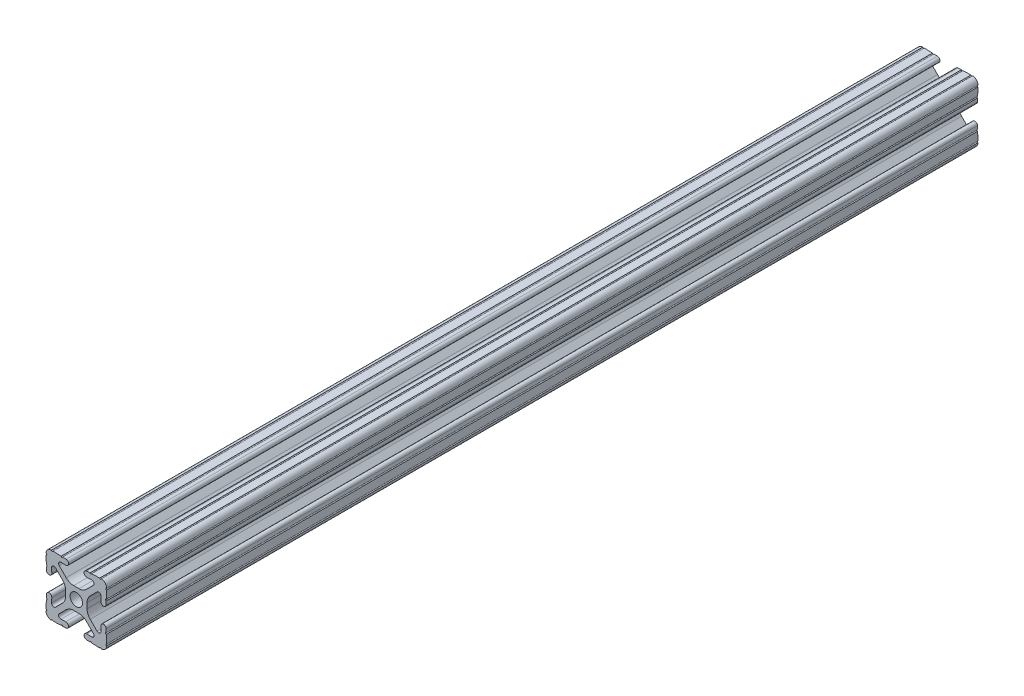
from build123d import *

# Parameters (mm, degrees)
SKETCH3_R      = 2.6035
EXTRUDE1_DEPTH = 182.5


with BuildPart() as part:
    # Sketch3 → Extrude1 (new body, symmetric)
    with BuildSketch(Plane.XY):
        with BuildLine():
            Line((-1.115277175, 4.5085), (1.115277175, 4.5085))
            ThreePointArc((1.115277175, 4.5085), (2.806584872, 4.844922018), (4.240406305, 5.80297087))
            Line((4.240406305, 5.80297087), (7.148423664, 8.710988229))
            ThreePointArc((7.148423664, 8.710988229), (7.349906316, 9.772227925), (6.436353897, 10.348636575))
            Line((6.436353897, 10.348636575), (4.381960454, 10.276895575))
            ThreePointArc((4.381960454, 10.276895575), (3.239173075, 11.342562046), (4.304839546, 12.485349424))
            Line((4.304839546, 12.485349424), (5.728246175, 12.535055879))
            ThreePointArc((5.728246175, 12.535055879), (6.054756855, 12.230579745), (6.35923299, 12.557090424))
            Line((6.35923299, 12.557090424), (9.782092278, 12.676619304))
            ThreePointArc((9.782092278, 12.676619304), (10.108602958, 12.37214317), (10.413079092, 12.69865385))
            ThreePointArc((10.413079092, 12.69865385), (12.052764565, 12.052764565), (12.69865385, 10.413079092))
            ThreePointArc((12.69865385, 10.413079092), (12.37214317, 10.108602958), (12.676619304, 9.782092278))
            Line((12.676619304, 9.782092278), (12.557090424, 6.35923299))
            ThreePointArc((12.557090424, 6.35923299), (12.230579745, 6.054756855), (12.535055879, 5.728246175))
            Line((12.535055879, 5.728246175), (12.485349424, 4.304839546))
            ThreePointArc((12.485349424, 4.304839546), (11.342562046, 3.239173075), (10.276895575, 4.381960454))
            Line((10.276895575, 4.381960454), (10.348636575, 6.436353897))
            ThreePointArc((10.348636575, 6.436353897), (9.772227925, 7.349906316), (8.710988229, 7.148423664))
            Line((8.710988229, 7.148423664), (5.80297087, 4.240406305))
            ThreePointArc((5.80297087, 4.240406305), (4.844922018, 2.806584872), (4.5085, 1.115277175))
            Line((4.5085, 1.115277175), (4.5085, -1.115277175))
            ThreePointArc((4.5085, -1.115277175), (4.844922018, -2.806584872), (5.80297087, -4.240406305))
            Line((5.80297087, -4.240406305), (8.710988229, -7.148423664))
            ThreePointArc((8.710988229, -7.148423664), (9.772227925, -7.349906316), (10.348636575, -6.436353897))
            Line((10.348636575, -6.436353897), (10.276895575, -4.381960454))
            ThreePointArc((10.276895575, -4.381960454), (11.342562046, -3.239173075), (12.485349424, -4.304839546))
            Line((12.485349424, -4.304839546), (12.535055879, -5.728246175))
            ThreePointArc((12.535055879, -5.728246175), (12.230579745, -6.054756855), (12.557090424, -6.35923299))
            Line((12.557090424, -6.35923299), (12.676619304, -9.782092278))
            ThreePointArc((12.676619304, -9.782092278), (12.37214317, -10.108602958), (12.69865385, -10.413079092))
            ThreePointArc((12.69865385, -10.413079092), (12.052764565, -12.052764565), (10.413079092, -12.69865385))
            ThreePointArc((10.413079092, -12.69865385), (10.108602958, -12.37214317), (9.782092278, -12.676619304))
            Line((9.782092278, -12.676619304), (6.35923299, -12.557090424))
            ThreePointArc((6.35923299, -12.557090424), (6.054756855, -12.230579745), (5.728246175, -12.535055879))
            Line((5.728246175, -12.535055879), (4.304839546, -12.485349424))
            ThreePointArc((4.304839546, -12.485349424), (3.239173075, -11.342562046), (4.381960454, -10.276895575))
            Line((4.381960454, -10.276895575), (6.436353897, -10.348636575))
            ThreePointArc((6.436353897, -10.348636575), (7.349906316, -9.772227925), (7.148423664, -8.710988229))
            Line((7.148423664, -8.710988229), (4.240406305, -5.80297087))
            ThreePointArc((4.240406305, -5.80297087), (2.806584872, -4.844922018), (1.115277175, -4.5085))
            Line((1.115277175, -4.5085), (-1.115277175, -4.5085))
            ThreePointArc((-1.115277175, -4.5085), (-2.806584872, -4.844922018), (-4.240406305, -5.80297087))
            Line((-4.240406305, -5.80297087), (-7.148423664, -8.710988229))
            ThreePointArc((-7.148423664, -8.710988229), (-7.349906316, -9.772227925), (-6.436353897, -10.348636575))
            Line((-6.436353897, -10.348636575), (-4.381960454, -10.276895575))
            ThreePointArc((-4.381960454, -10.276895575), (-3.239173075, -11.342562046), (-4.304839546, -12.485349424))
            Line((-4.304839546, -12.485349424), (-5.728246175, -12.535055879))
            ThreePointArc((-5.728246175, -12.535055879), (-6.054756855, -12.230579745), (-6.35923299, -12.557090424))
            Line((-6.35923299, -12.557090424), (-9.782092278, -12.676619304))
            ThreePointArc((-9.782092278, -12.676619304), (-10.108602958, -12.37214317), (-10.413079092, -12.69865385))
            ThreePointArc((-10.413079092, -12.69865385), (-12.052764565, -12.052764565), (-12.69865385, -10.413079092))
            ThreePointArc((-12.69865385, -10.413079092), (-12.37214317, -10.108602958), (-12.676619304, -9.782092278))
            Line((-12.676619304, -9.782092278), (-12.557090424, -6.35923299))
            ThreePointArc((-12.557090424, -6.35923299), (-12.230579745, -6.054756855), (-12.535055879, -5.728246175))
            Line((-12.535055879, -5.728246175), (-12.485349424, -4.304839546))
            ThreePointArc((-12.485349424, -4.304839546), (-11.342562046, -3.239173075), (-10.276895575, -4.381960454))
            Line((-10.276895575, -4.381960454), (-10.348636575, -6.436353897))
            ThreePointArc((-10.348636575, -6.436353897), (-9.772227925, -7.349906316), (-8.710988229, -7.148423664))
            Line((-8.710988229, -7.148423664), (-5.80297087, -4.240406305))
            ThreePointArc((-5.80297087, -4.240406305), (-4.844922018, -2.806584872), (-4.5085, -1.115277175))
            Line((-4.5085, -1.115277175), (-4.5085, 1.115277175))
            ThreePointArc((-4.5085, 1.115277175), (-4.844922018, 2.806584872), (-5.80297087, 4.240406305))
            Line((-5.80297087, 4.240406305), (-8.710988229, 7.148423664))
            ThreePointArc((-8.710988229, 7.148423664), (-9.772227925, 7.349906316), (-10.348636575, 6.436353897))
            Line((-10.348636575, 6.436353897), (-10.276895575, 4.381960454))
            ThreePointArc((-10.276895575, 4.381960454), (-11.342562046, 3.239173075), (-12.485349424, 4.304839546))
            Line((-12.485349424, 4.304839546), (-12.535055879, 5.728246175))
            ThreePointArc((-12.535055879, 5.728246175), (-12.230579745, 6.054756855), (-12.557090424, 6.35923299))
            Line((-12.557090424, 6.35923299), (-12.676619304, 9.782092278))
            ThreePointArc((-12.676619304, 9.782092278), (-12.37214317, 10.108602958), (-12.69865385, 10.413079092))
            ThreePointArc((-12.69865385, 10.413079092), (-12.052764565, 12.052764565), (-10.413079092, 12.69865385))
            ThreePointArc((-10.413079092, 12.69865385), (-10.108602958, 12.37214317), (-9.782092278, 12.676619304))
            Line((-9.782092278, 12.676619304), (-6.35923299, 12.557090424))
            ThreePointArc((-6.35923299, 12.557090424), (-6.054756855, 12.230579745), (-5.728246175, 12.535055879))
            Line((-5.728246175, 12.535055879), (-4.304839546, 12.485349424))
            ThreePointArc((-4.304839546, 12.485349424), (-3.239173075, 11.342562046), (-4.381960454, 10.276895575))
            Line((-4.381960454, 10.276895575), (-6.436353897, 10.348636575))
            ThreePointArc((-6.436353897, 10.348636575), (-7.349906316, 9.772227925), (-7.148423664, 8.710988229))
            Line((-7.148423664, 8.710988229), (-4.240406305, 5.80297087))
            ThreePointArc((-4.240406305, 5.80297087), (-2.806584872, 4.844922018), (-1.115277175, 4.5085))
        make_face()
        Circle(SKETCH3_R, mode=Mode.SUBTRACT)
    extrude(amount=EXTRUDE1_DEPTH, both=True)


solid = part.part
